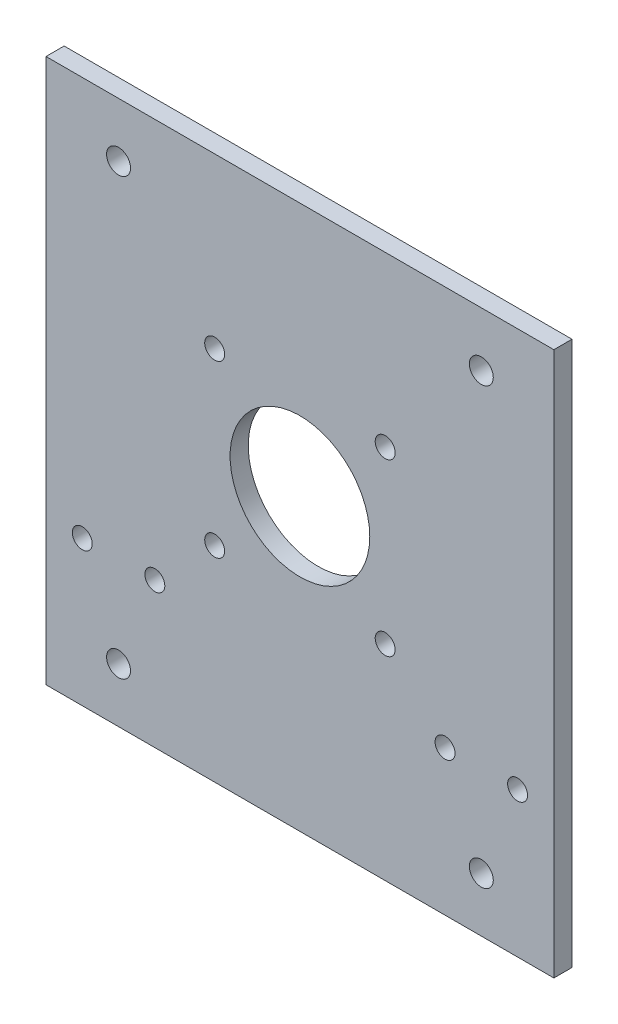
from build123d import *

# Parameters (mm, degrees)
SKETCH1_W             = 140
SKETCH1_H             = 150
SKETCH1_R             = 2.75
SKETCH1_R_2           = 19.25
BOSS_EXTRUDE1_DEPTH   = 5
F_5_0MM_DOWEL_HOLE1_D = 5.5
F_6_0MM_DOWEL_HOLE2_D = 6.6


with BuildPart() as part:
    # Sketch1 → Boss-Extrude1 (new body)
    with BuildSketch(Plane.XY):
        with Locations((0, -11)):
            Rectangle(SKETCH1_W, SKETCH1_H)
        with Locations((23.5, 17.5)):
            Circle(SKETCH1_R, mode=Mode.SUBTRACT)
        with Locations((-23.5, 17.5)):
            Circle(SKETCH1_R, mode=Mode.SUBTRACT)
        with Locations((-23.5, -29.5)):
            Circle(SKETCH1_R, mode=Mode.SUBTRACT)
        with Locations((23.5, -29.5)):
            Circle(SKETCH1_R, mode=Mode.SUBTRACT)
        with Locations((0, -6)):
            Circle(SKETCH1_R_2, mode=Mode.SUBTRACT)
    extrude(amount=BOSS_EXTRUDE1_DEPTH)

    # Ø5.0mm Dowel Hole1 (through all)
    with Locations(Plane(origin=(60, -46, 0), x_dir=(-1, 0, 0), z_dir=(0, 0, -1))):
        with Locations((0, 0), (120, 0), (100, 0), (20, 0)):
            Hole(F_5_0MM_DOWEL_HOLE1_D / 2)

    # Ø6.0mm Dowel Hole2 (through all)
    with Locations(Plane(origin=(-50, 49, 5), x_dir=(1, 0, 0), z_dir=(0, 0, 1))):
        with Locations((0, 0), (100, 0), (100, -120), (0, -120)):
            Hole(F_6_0MM_DOWEL_HOLE2_D / 2)


solid = part.part
